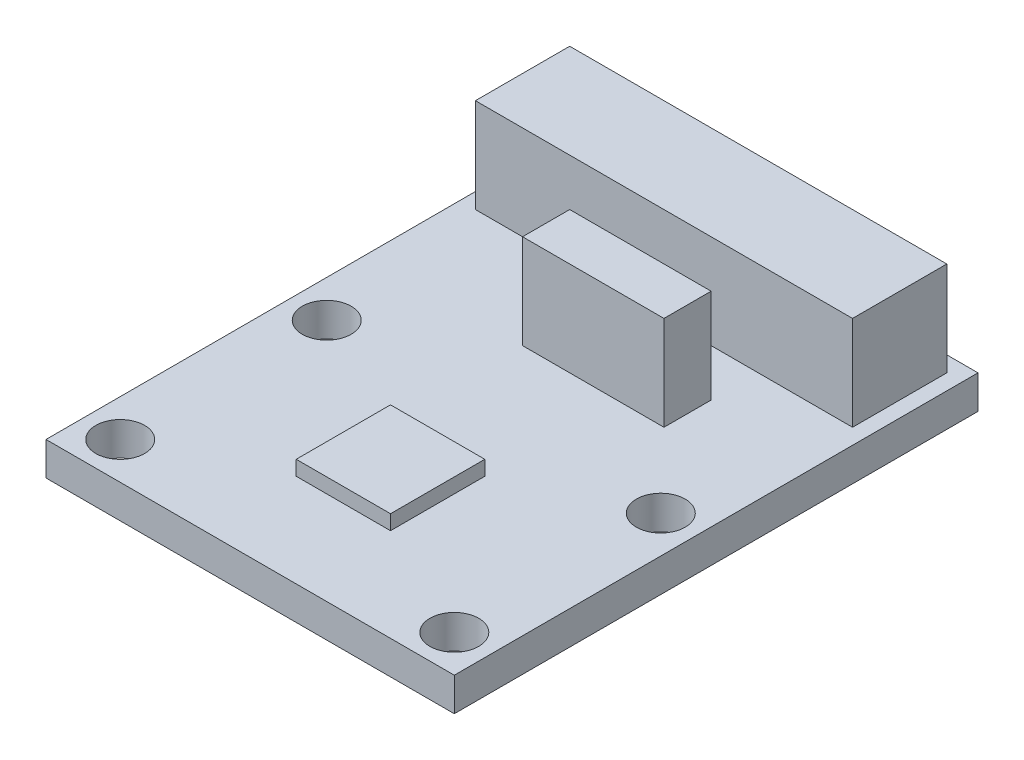
from build123d import *

# Parameters (mm, degrees)
SKETCH1_W           = 22
SKETCH1_H           = 28.216692514
SKETCH1_R           = 1.315
BOSS_EXTRUDE1_DEPTH = 1.8
SKETCH2_W           = 5.08
SKETCH2_H           = 5.08
BOSS_EXTRUDE2_DEPTH = 0.79375
BOSS_EXTRUDE3_START = -1.8
SKETCH3_W           = 7.62
SKETCH3_H           = 2.54
SKETCH3_W_2         = 20.32
SKETCH3_H_2         = 5.08
BOSS_EXTRUDE3_DEPTH = 5.08


with BuildPart() as part:
    # Sketch1 → Boss-Extrude1 (new body)
    with BuildSketch(Plane(origin=(0, 0, 0), x_dir=(1, 0, 0), z_dir=(0, 1, 0))):
        with Locations((0, 6.545846257)):
            Rectangle(SKETCH1_W, SKETCH1_H)
        with Locations((-9, 5.5625)):
            Circle(SKETCH1_R, mode=Mode.SUBTRACT)
        with Locations((9, 5.5625)):
            Circle(SKETCH1_R, mode=Mode.SUBTRACT)
        with Locations((9, -5.5625)):
            Circle(SKETCH1_R, mode=Mode.SUBTRACT)
        with Locations((-9, -5.5625)):
            Circle(SKETCH1_R, mode=Mode.SUBTRACT)
    extrude(amount=BOSS_EXTRUDE1_DEPTH)

    # Sketch2 → Boss-Extrude2 (add)
    with BuildSketch(Plane(origin=(0, 1.8, 0), x_dir=(1, 0, 0), z_dir=(0, 1, 0))):
        Rectangle(SKETCH2_W, SKETCH2_H)
    extrude(amount=BOSS_EXTRUDE2_DEPTH)

    # Sketch3 → Boss-Extrude3 (add)
    with BuildSketch(Plane(origin=(0, 0, 0), x_dir=(-1, 0, 0), z_dir=(0, -1, 0)).offset(BOSS_EXTRUDE3_START)):
        with Locations((-1.27, 10.924192514)):
            Rectangle(SKETCH3_W, SKETCH3_H)
        with Locations((0, 17.274192514)):
            Rectangle(SKETCH3_W_2, SKETCH3_H_2)
    extrude(amount=-BOSS_EXTRUDE3_DEPTH)


solid = part.part
